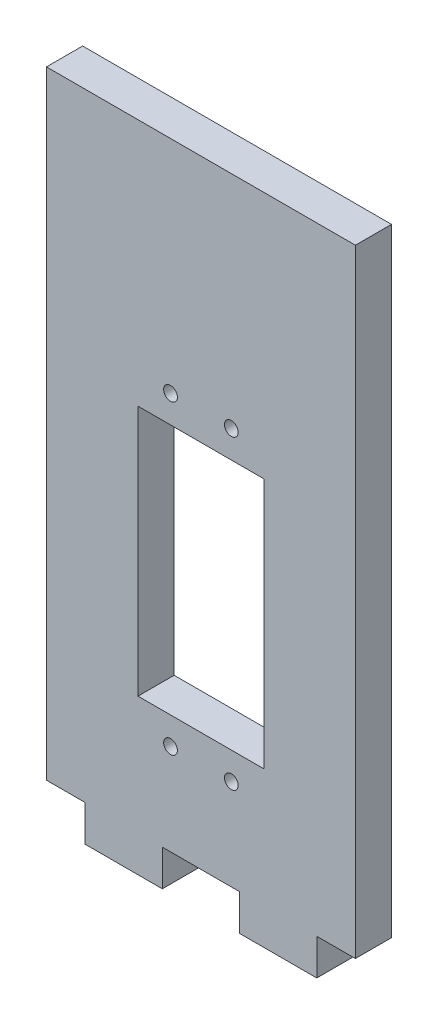
from build123d import *

# Parameters (mm, degrees)
BOSS_EXTRUDE1_DEPTH = 5.9436
SKETCH2_R           = 1.1303
SKETCH2_W           = 20.7
SKETCH2_H           = 41.3
CUT_EXTRUDE1_DEPTH  = 6.9436


with BuildPart() as part:
    # Sketch1 → Boss-Extrude1 (new body)
    with BuildSketch(Plane.XY):
        Polygon((6.35, 0), (6.35, -5.9436), (19.05, -5.9436), (19.05, 0), (31.75, 0), (31.75, -5.9436), (44.45, -5.9436), (44.45, 0), (50.8, 0), (50.8, 101.6), (0, 101.6), (0, 0), align=None)
    extrude(amount=BOSS_EXTRUDE1_DEPTH)

    # Sketch2 → Cut-Extrude1 (cut, through all)
    with BuildSketch(Plane.XY.offset(5.9436)):
        with Locations((20.4, 65.3)):
            Circle(SKETCH2_R)
        with Locations((30.4, 65.3)):
            Circle(SKETCH2_R)
        with Locations((20.4, 15)):
            Circle(SKETCH2_R)
        with Locations((30.4, 15)):
            Circle(SKETCH2_R)
        with Locations((25.4, 40.15)):
            Rectangle(SKETCH2_W, SKETCH2_H)
    extrude(amount=-CUT_EXTRUDE1_DEPTH, mode=Mode.SUBTRACT)


solid = part.part
